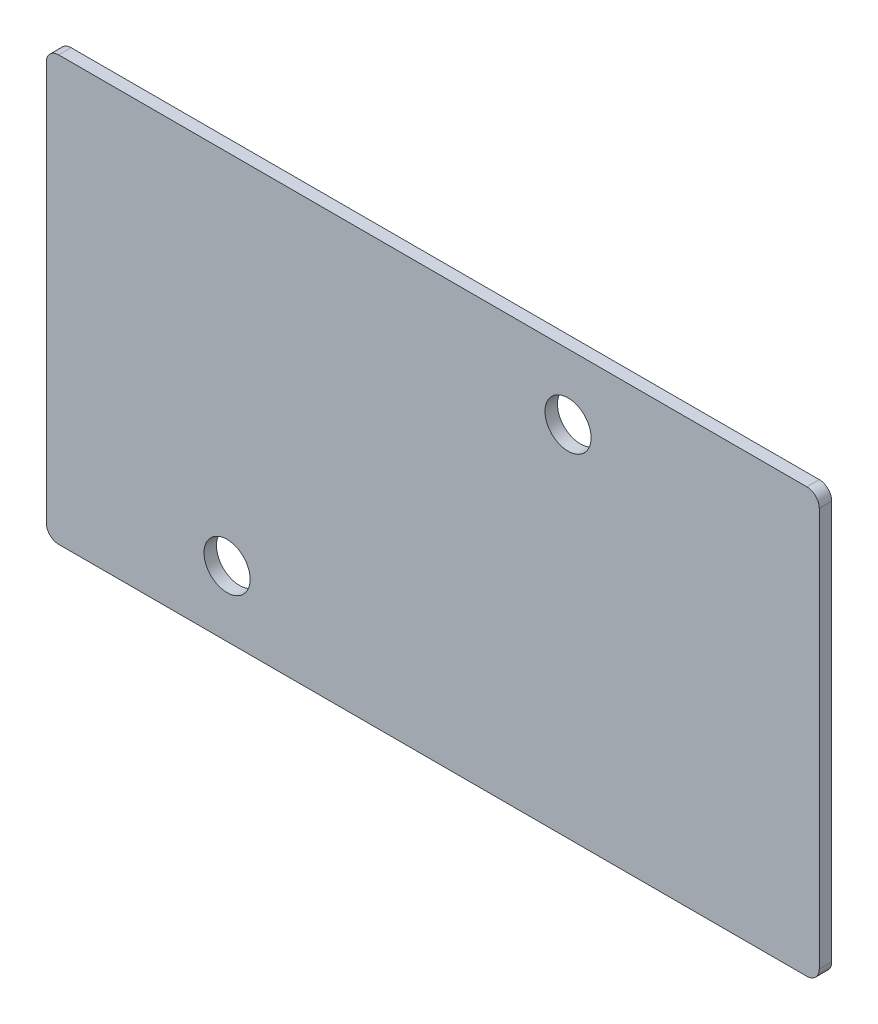
from build123d import *

# Parameters (mm, degrees)
CROQUIS1_R              = 1.85
SALIENTE_EXTRUIR1_DEPTH = 1


with BuildPart() as part:
    # Croquis1 → Saliente-Extruir1 (new body)
    with BuildSketch(Plane.XY):
        with BuildLine():
            Line((-5, 31.75), (55, 31.75))
            ThreePointArc((55, 31.75), (55.707106781, 31.457106781), (56, 30.75))
            Line((56, 30.75), (56, -1.25))
            ThreePointArc((56, -1.25), (55.707106781, -1.957106781), (55, -2.25))
            Line((55, -2.25), (-5, -2.25))
            ThreePointArc((-5, -2.25), (-5.707106781, -1.957106781), (-6, -1.25))
            Line((-6, -1.25), (-6, 30.75))
            ThreePointArc((-6, 30.75), (-5.707106781, 31.457106781), (-5, 31.75))
        make_face()
        with Locations((35.85, 26.5)):
            Circle(CROQUIS1_R, mode=Mode.SUBTRACT)
        with Locations((8.5, 3)):
            Circle(CROQUIS1_R, mode=Mode.SUBTRACT)
    extrude(amount=SALIENTE_EXTRUIR1_DEPTH)


solid = part.part
